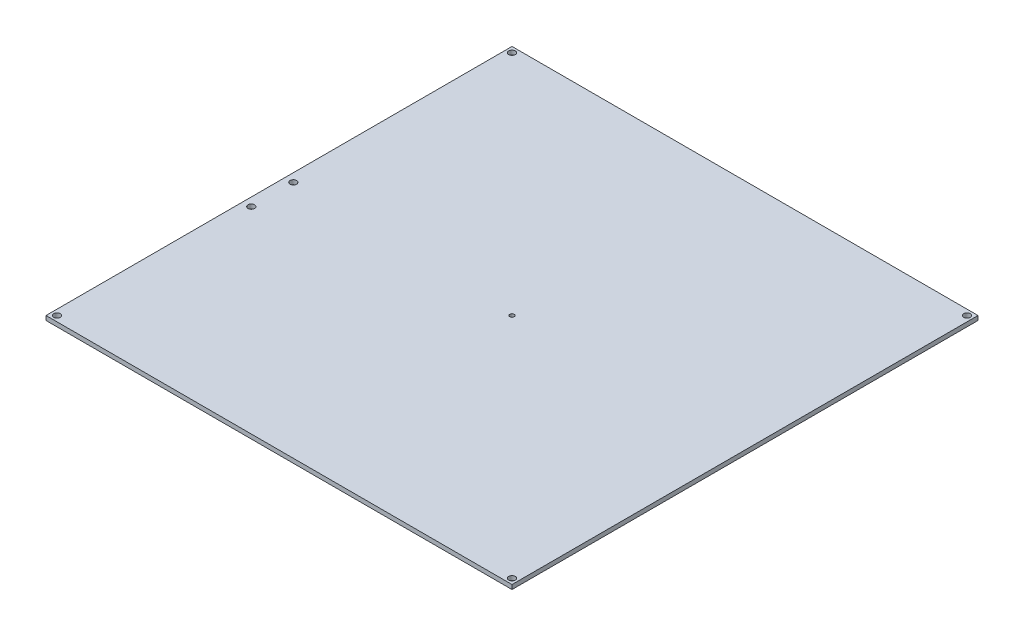
from build123d import *

# Parameters (mm, degrees)
SKETCH_1_W          = 214
SKETCH_1_H          = 214
SKETCH_1_R          = 1.5
SKETCH_1_R_2        = 1
EXTRUDE_1_DEPTH     = 2
SKETCH_4_R          = 1.5
CUT_EXTRUDE_1_DEPTH = 3


with BuildPart() as part:
    # Эскиз1 → Бобышка-Вытянуть1 (new body)
    with BuildSketch(Plane(origin=(0, 0, 0), x_dir=(1, 0, 0), z_dir=(0, 1, 0))):
        Rectangle(SKETCH_1_W, SKETCH_1_H)
        with Locations((-104.5, 104.5)):
            Circle(SKETCH_1_R, mode=Mode.SUBTRACT)
        with Locations((104.5, 104.5)):
            Circle(SKETCH_1_R, mode=Mode.SUBTRACT)
        with Locations((104.5, -104.5)):
            Circle(SKETCH_1_R, mode=Mode.SUBTRACT)
        with Locations((-104.5, -104.5)):
            Circle(SKETCH_1_R, mode=Mode.SUBTRACT)
        Circle(SKETCH_1_R_2, mode=Mode.SUBTRACT)
    extrude(amount=EXTRUDE_1_DEPTH)

    # Эскиз4 → Вырез-Вытянуть1 (cut, through all)
    with BuildSketch(Plane(origin=(0, 2, 0), x_dir=(1, 0, 0), z_dir=(0, 1, 0))):
        with Locations((-103.153252948, 2.740781497)):
            Circle(SKETCH_4_R)
        with Locations((-103.153252948, -16.573740768)):
            Circle(SKETCH_4_R)
    extrude(amount=-CUT_EXTRUDE_1_DEPTH, mode=Mode.SUBTRACT)


solid = part.part
